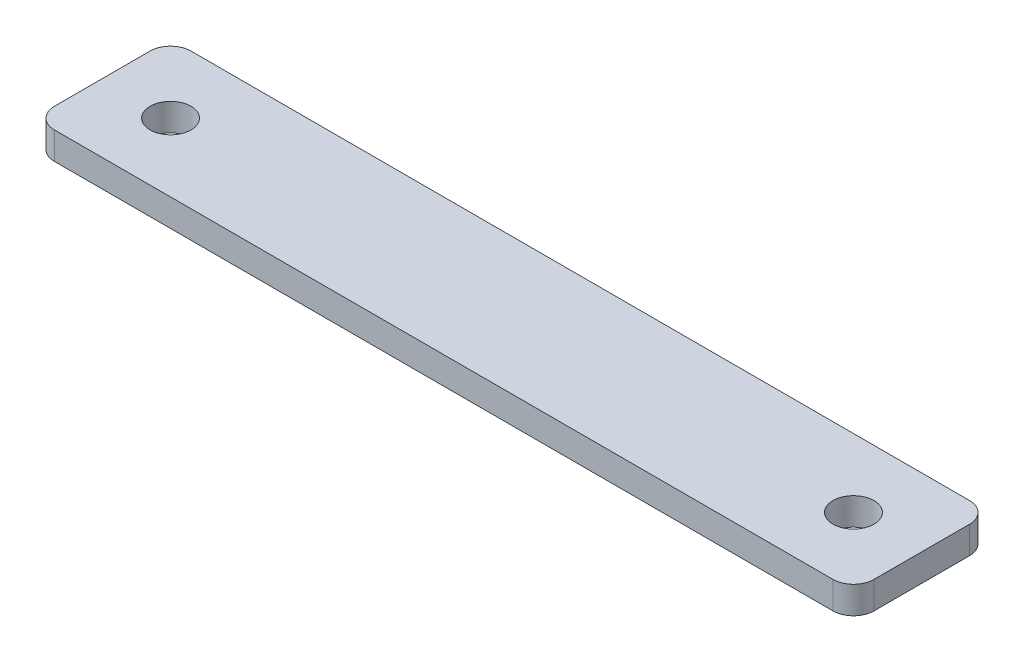
from build123d import *

# Parameters (mm, degrees)
SKETCH1_W           = 120
SKETCH1_H           = 20
BOSS_EXTRUDE1_DEPTH = 4
SKETCH2_R           = 3
CUT_EXTRUDE1_DEPTH  = 4
FILLET1_R           = 3


with BuildPart() as part:
    # Sketch1 → Boss-Extrude1 (new body)
    with BuildSketch(Plane(origin=(0, 0, 0), x_dir=(1, 0, 0), z_dir=(0, 1, 0))):
        Rectangle(SKETCH1_W, SKETCH1_H)
    extrude(amount=BOSS_EXTRUDE1_DEPTH)

    # Sketch2 → Cut-Extrude1 (cut)
    with BuildSketch(Plane(origin=(0, 4, 0), x_dir=(1, 0, 0), z_dir=(0, 1, 0))):
        with Locations((-50, 0)):
            Circle(SKETCH2_R)
        with Locations((50, 0)):
            Circle(SKETCH2_R)
    extrude(amount=-CUT_EXTRUDE1_DEPTH, mode=Mode.SUBTRACT)

    # Fillet1
    fillet1_edges = [part.edges().sort_by_distance(p)[0] for p in [
        (60, 2, 10),
        (-60, 2, 10),
        (-60, 2, -10),
        (60, 2, -10),
    ]]
    fillet(fillet1_edges, radius=FILLET1_R)


solid = part.part
